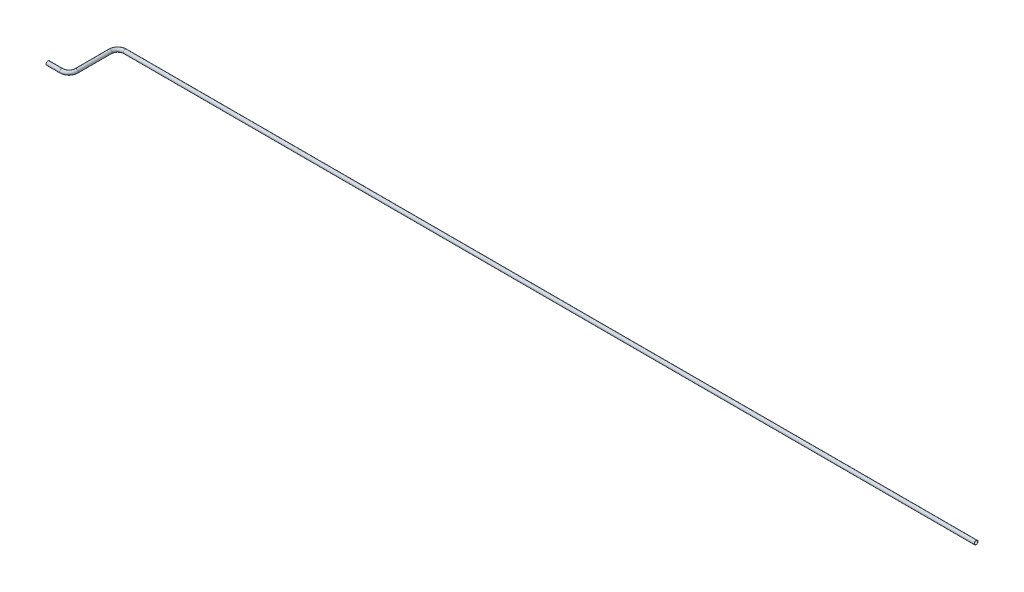
from build123d import *

# Parameters (mm, degrees)
SKETCH5_R   = 3.175
SKETCH5_R_2 = 2.667


with BuildPart() as part:
    # Sweep3: sweep along a curve in space
    with BuildLine() as sweep3_path:
        Line((0, 0, 0), (22.86, 0, 0))
        ThreePointArc((22.86, 0, 0), (31.840256121, 0, -3.719743879), (35.56, 0, -12.7))
        Line((35.56, 0, -12.7), (35.56, 0, -69.48826463))
        ThreePointArc((35.56, 0, -69.48826463), (39.279743879, 0, -78.468520751), (48.26, 0, -82.18826463))
        Line((48.26, 0, -82.18826463), (1483.36, 0, -82.18826463))
    # Sketch5 → Sweep3 (sweep)
    with BuildSketch(Plane(origin=(0, 0, 0), x_dir=(0, 0, -1), z_dir=(1, 0, 0))):
        Circle(SKETCH5_R)
        Circle(SKETCH5_R_2, mode=Mode.SUBTRACT)
    sweep(path=sweep3_path.line)


solid = part.part
